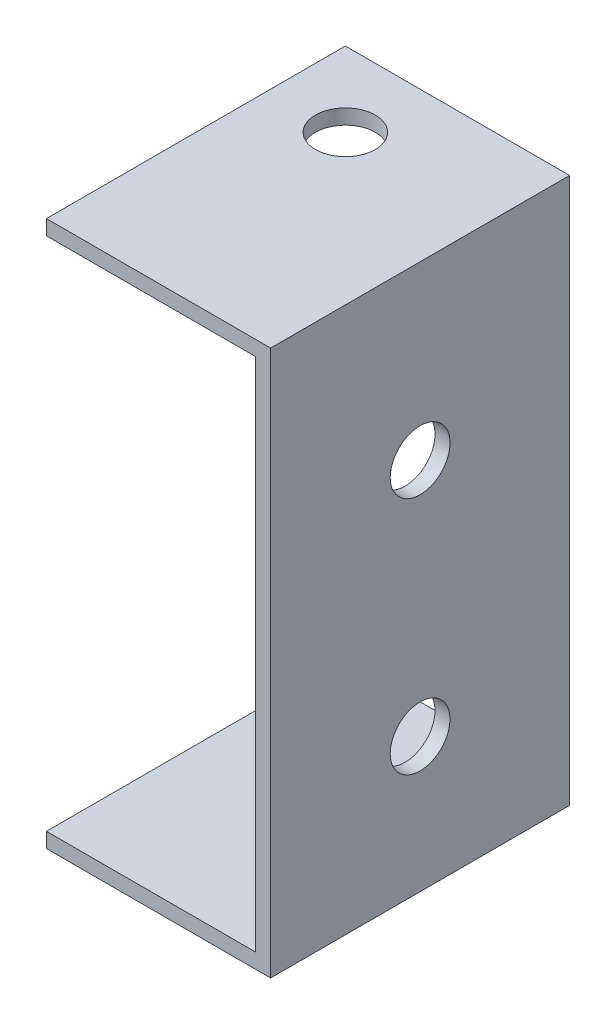
from build123d import *

# Parameters (mm, degrees)
EXTRUDE_1_DEPTH     = 40
SKETCH_3_R          = 4
CUT_EXTRUDE_1_DEPTH = 40
SKETCH_4_R          = 4
CUT_EXTRUDE_2_DEPTH = 96


with BuildPart() as part:
    # 草图1 → 凸台-拉伸1 (new body)
    with BuildSketch(Plane.XY):
        Polygon((-61.165760894, 46.995024588), (-31.165760894, 46.995024588), (-31.165760894, -26.004975412), (-61.165760894, -26.004975412), (-61.165760894, -24.004975412), (-33.165760894, -24.004975412), (-33.165760894, 44.995024588), (-61.165760894, 44.995024588), align=None)
    extrude(amount=EXTRUDE_1_DEPTH)

    # 草图3 → 切除-拉伸1 (cut)
    with BuildSketch(Plane.ZY.offset(33.165760894)):
        with Locations((20, 23.995024588)):
            Circle(SKETCH_3_R)
        with Locations((20, -8.004975412)):
            Circle(SKETCH_3_R)
    extrude(amount=-CUT_EXTRUDE_1_DEPTH, mode=Mode.SUBTRACT)

    # 草图4 → 切除-拉伸2 (cut)
    with BuildSketch(Plane(origin=(0, 46.995024588, 0), x_dir=(1, 0, 0), z_dir=(0, 1, 0))):
        with Locations((-51.165760894, -10)):
            Circle(SKETCH_4_R)
    extrude(amount=-CUT_EXTRUDE_2_DEPTH, mode=Mode.SUBTRACT)


solid = part.part
